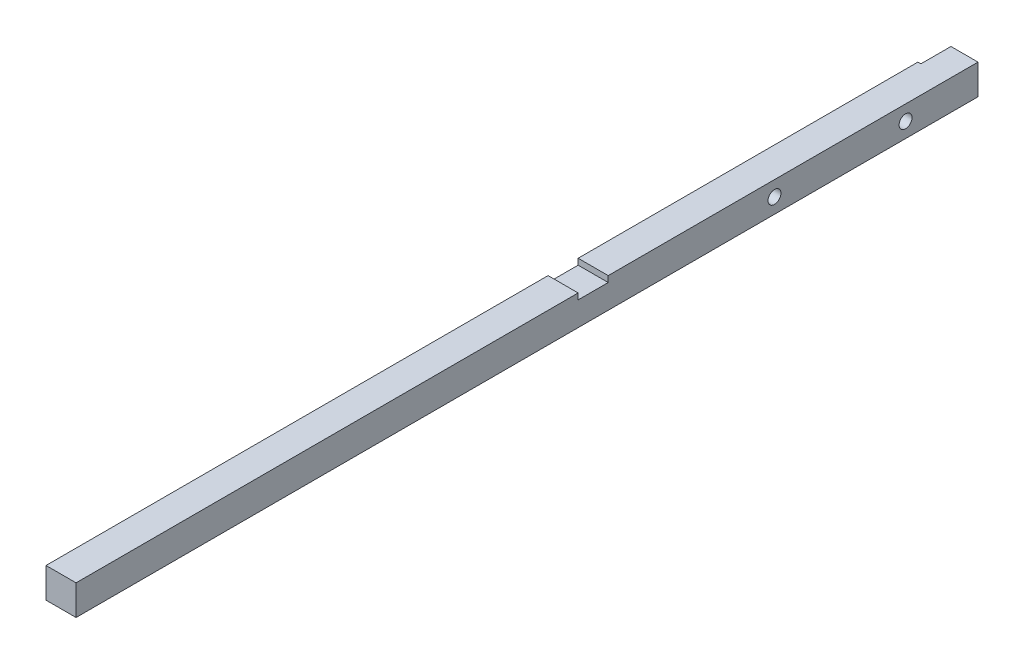
from build123d import *

# Parameters (mm, degrees)
BOSS_EXTRU_1_START      = 7
ESQUISSE1_W             = 10
ESQUISSE1_H             = 10
BOSS_EXTRU_1_DEPTH      = 300
ESQUISSE4_W             = 10
ESQUISSE4_H             = 2
ENL_V_MAT_EXTRU_3_DEPTH = 11
ESQUISSE6_W             = 10
ESQUISSE6_H             = 10
ENL_V_MAT_EXTRU_5_DEPTH = 1
D_GAGEMENT_M41_D        = 4.3


with BuildPart() as part:
    # Esquisse1 → Boss.-Extru.1 (new body)
    with BuildSketch(Plane.XY.offset(BOSS_EXTRU_1_START)):
        Rectangle(ESQUISSE1_W, ESQUISSE1_H)
    extrude(amount=BOSS_EXTRU_1_DEPTH)

    # Esquisse4 → Enlèv. mat.-Extru.3 (cut, through all)
    with BuildSketch(Plane(origin=(5, 0, 0), x_dir=(0, 0, -1), z_dir=(1, 0, 0))):
        with Locations((-135, 4)):
            Rectangle(ESQUISSE4_W, ESQUISSE4_H)
    extrude(amount=-ENL_V_MAT_EXTRU_3_DEPTH, mode=Mode.SUBTRACT)

    # Esquisse6 → Enlèv. mat.-Extru.5 (cut)
    with BuildSketch(Plane.ZY.offset(5)):
        with Locations((12, 0)):
            Rectangle(ESQUISSE6_W, ESQUISSE6_H)
    extrude(amount=-ENL_V_MAT_EXTRU_5_DEPTH, mode=Mode.SUBTRACT)

    # Dégagement M41 (through all)
    with Locations(Plane.ZY.offset(5)):
        with Locations((74.69, 0), (31.09, 0)):
            Hole(D_GAGEMENT_M41_D / 2)


solid = part.part
